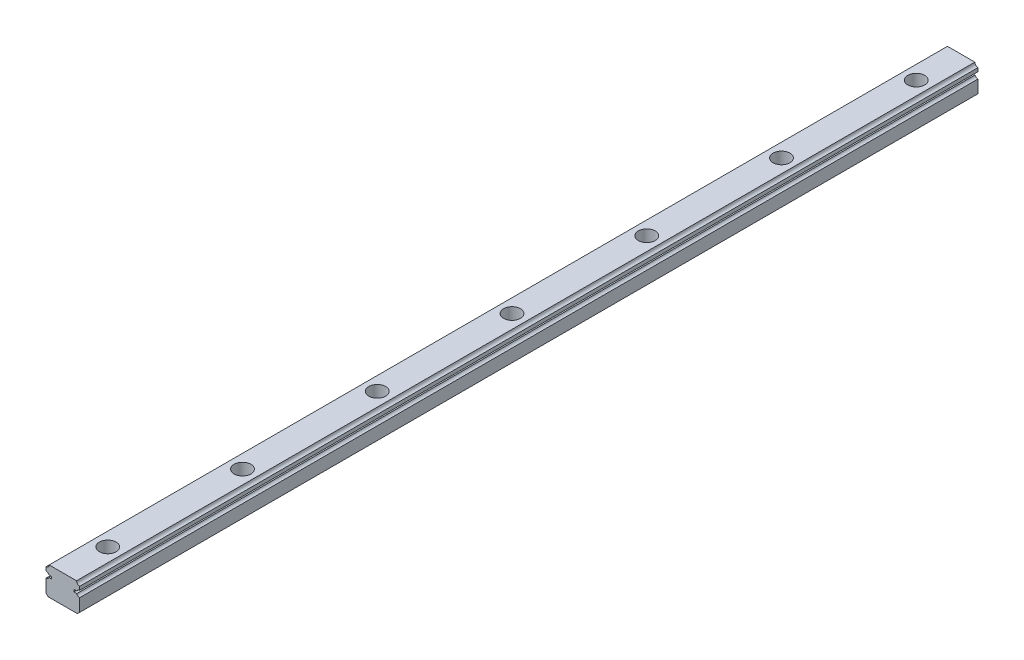
from build123d import *

# Parameters (mm, degrees)
EXTRUDE1_DEPTH  = 200
LPATTERN1_COUNT = 6
LPATTERN1_PITCH = 60


with BuildPart() as part:
    # 15mm → Extrude1 (new, symmetric)
    with BuildSketch(Plane.XY):
        with BuildLine():
            Line((4.949972, 7.600006), (6.192321846, 7.599996))
            ThreePointArc((6.192321846, 7.599996), (6.706266371, 6.946742527), (7.49999, 6.7))
            Line((7.49999, 6.7), (7.49999, 1.000024142))
            Line((7.49999, 1.000024142), (6.499965858, 0))
            Line((6.499965858, 0), (-6.499965858, 0))
            Line((-6.499965858, 0), (-7.49999, 1.000024142))
            Line((-7.49999, 1.000024142), (-7.49999, 6.7))
            ThreePointArc((-7.49999, 6.7), (-6.70626637, 6.946742527), (-6.192321846, 7.599996))
            Line((-6.192321846, 7.599996), (-4.949982, 7.599996))
            Line((-4.949982, 7.599996), (-4.949972, 8.600006))
            Line((-4.949972, 8.600006), (-6.192326435, 8.600016))
            ThreePointArc((-6.192326435, 8.600016), (-6.706271662, 9.253261115), (-7.49999, 9.5))
            Line((-7.49999, 9.5), (-7.49999, 11.099974))
            ThreePointArc((-7.49999, 11.099974), (-6.510037425, 11.510033031), (-6.099989, 12.49999))
            Line((-6.099989, 12.49999), (6.099989, 12.49999))
            ThreePointArc((6.099989, 12.49999), (6.510037425, 11.510033031), (7.49999, 11.099974))
            Line((7.49999, 11.099974), (7.49999, 9.5))
            ThreePointArc((7.49999, 9.5), (6.706271662, 9.253261115), (6.192326435, 8.600016))
            Line((6.192326435, 8.600016), (4.949982, 8.600016))
            Line((4.949982, 8.600016), (4.949972, 7.600006))
        make_face()
    extrude(amount=EXTRUDE1_DEPTH, both=True)

    # Sketch1 → Cut-Revolve1 (revolve, cut)
    with BuildSketch(Plane(origin=(0, 0, 0), x_dir=(0, 0, -1), z_dir=(1, 0, 0))):
        Polygon((-180, 12.49999), (-176.25, 12.49999), (-176.25, 7.19999), (-177.75, 7.19999), (-177.75, 0), (-180, 0), align=None)
    revolve(axis=Axis((0, 0, 180), (0, 1, 0)), mode=Mode.SUBTRACT)

    # Sketch2 → Cut-Revolve2 (revolve, cut)
    with BuildSketch(Plane(origin=(0, 0, 0), x_dir=(0, 0, -1), z_dir=(1, 0, 0))):
        Polygon((180, 0), (182.25, 0), (182.25, 7.19999), (183.75, 7.19999), (183.75, 12.49999), (180, 12.49999), align=None)
    cut_revolve2 = revolve(axis=Axis((0, 12.49999, -180), (0, -1, 0)), mode=Mode.SUBTRACT)

    # LPattern1: Cut-Revolve2 ×6
    with Locations(*[(0, 0, i * LPATTERN1_PITCH) for i in range(1, LPATTERN1_COUNT)]):
        add(cut_revolve2, mode=Mode.SUBTRACT)


solid = part.part
